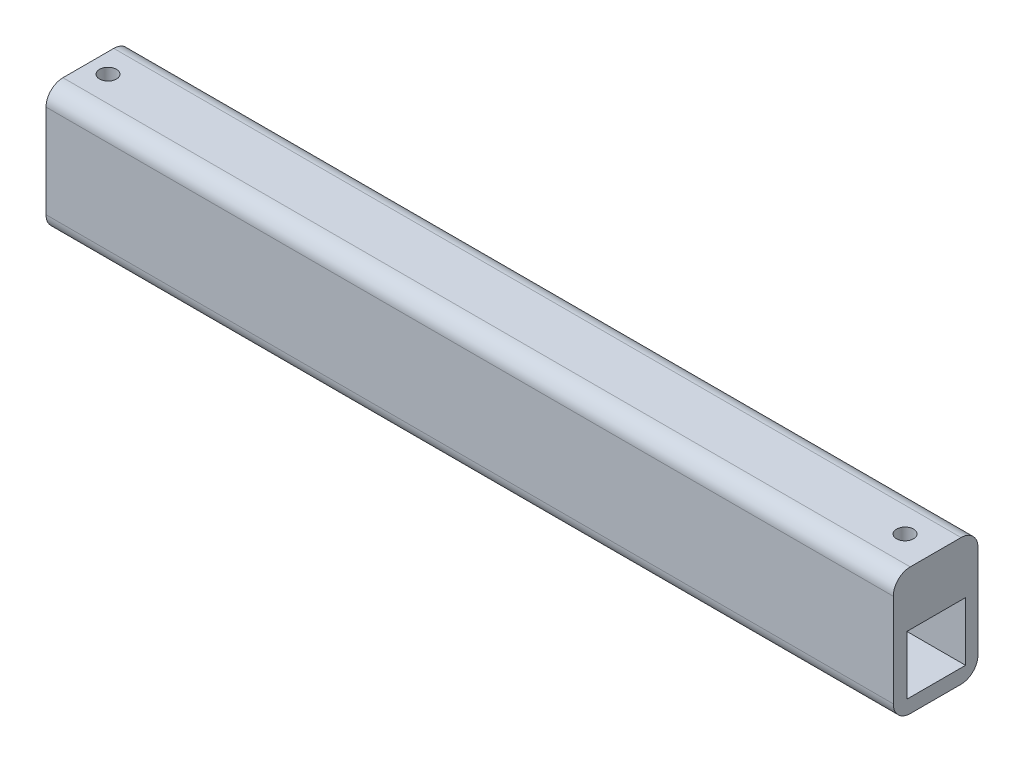
from build123d import *

# Parameters (mm, degrees)
SKETCH1_W           = 200
SKETCH1_H           = 30
BOSS_EXTRUDE1_DEPTH = 20
FILLET8_R           = 4
SKETCH3_W           = 13.877219135
SKETCH3_H           = 13.846786638
CUT_EXTRUDE1_DEPTH  = 200
SKETCH4_R           = 2
CUT_EXTRUDE2_DEPTH  = 20
SKETCH5_R           = 2
CUT_EXTRUDE3_DEPTH  = 20


with BuildPart() as part:
    # Sketch1 → Boss-Extrude1 (new body)
    with BuildSketch(Plane.XY):
        with Locations((10.755148741, -6.167048055)):
            Rectangle(SKETCH1_W, SKETCH1_H)
    extrude(amount=BOSS_EXTRUDE1_DEPTH)

    # Fillet8
    fillet8_edges = [part.edges().sort_by_distance(p)[0] for p in [
        (10.755148741, 8.832951945, 20),
        (10.755148741, 8.832951945, 0),
        (10.755148741, -21.167048055, 0),
        (10.755148741, -21.167048055, 20),
    ]]
    fillet(fillet8_edges, radius=FILLET8_R)

    # Sketch3 → Cut-Extrude1 (cut)
    with BuildSketch(Plane.ZY.offset(89.244851259)):
        with Locations((9.878270008, -10.893155572)):
            Rectangle(SKETCH3_W, SKETCH3_H)
    extrude(amount=-CUT_EXTRUDE1_DEPTH, mode=Mode.SUBTRACT)

    # Sketch4 → Cut-Extrude2 (cut)
    with BuildSketch(Plane(origin=(0, 8.832951945, 0), x_dir=(1, 0, 0), z_dir=(0, 1, 0))):
        with Locations((-84.647114684, -9.960432704)):
            Circle(SKETCH4_R)
    extrude(amount=-CUT_EXTRUDE2_DEPTH, mode=Mode.SUBTRACT)

    # Sketch5 → Cut-Extrude3 (cut)
    with BuildSketch(Plane(origin=(0, 8.832951945, 0), x_dir=(1, 0, 0), z_dir=(0, 1, 0))):
        with Locations((103.408272514, -9.882419894)):
            Circle(SKETCH5_R)
    extrude(amount=-CUT_EXTRUDE3_DEPTH, mode=Mode.SUBTRACT)


solid = part.part
